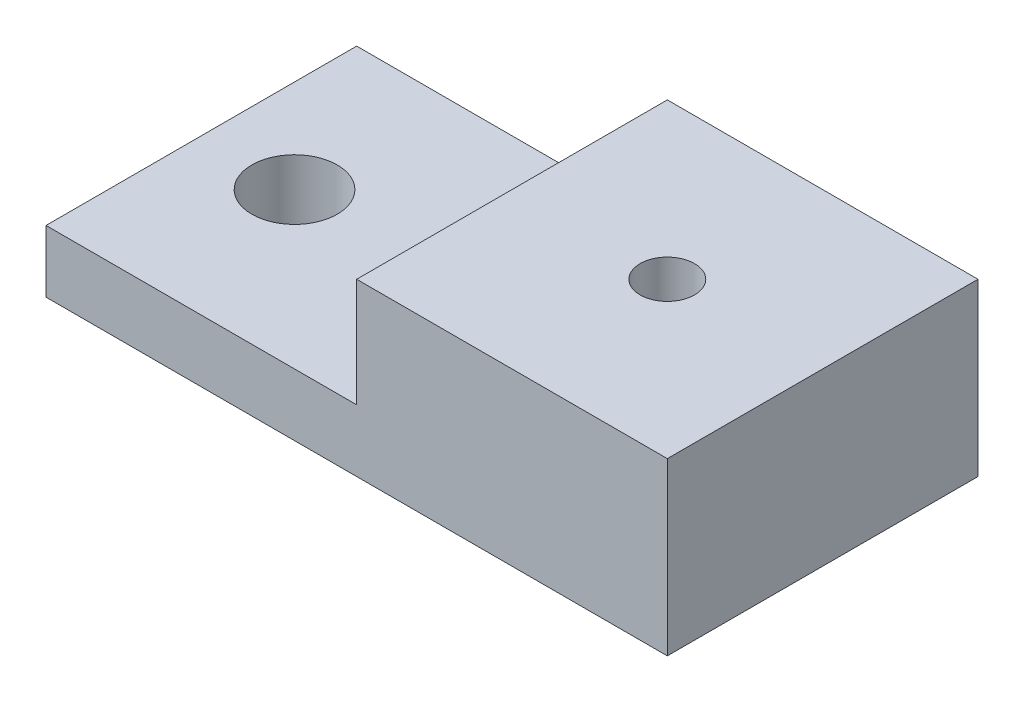
from build123d import *

# Parameters (mm, degrees)
SKETCH1_W           = 40
SKETCH1_H           = 20
SKETCH1_R           = 2.75
BOSS_EXTRUDE1_DEPTH = 4
SKETCH2_W           = 20
SKETCH2_H           = 20
BOSS_EXTRUDE2_DEPTH = 7
SKETCH3_R           = 1.75
CUT_EXTRUDE1_DEPTH  = 12
CUT_EXTRUDE2_DEPTH  = 7


with BuildPart() as part:
    # Sketch1 → Boss-Extrude1 (new body)
    with BuildSketch(Plane(origin=(0, 0, 0), x_dir=(1, 0, 0), z_dir=(0, 1, 0))):
        with Locations((20, 10)):
            Rectangle(SKETCH1_W, SKETCH1_H)
        with Locations((6, 10)):
            Circle(SKETCH1_R, mode=Mode.SUBTRACT)
    extrude(amount=BOSS_EXTRUDE1_DEPTH)

    # Sketch2 → Boss-Extrude2 (add)
    with BuildSketch(Plane(origin=(0, 4, 0), x_dir=(1, 0, 0), z_dir=(0, 1, 0))):
        with Locations((30, 10)):
            Rectangle(SKETCH2_W, SKETCH2_H)
    extrude(amount=BOSS_EXTRUDE2_DEPTH)

    # Sketch3 → Cut-Extrude1 (cut, through all)
    with BuildSketch(Plane(origin=(0, 11, 0), x_dir=(1, 0, 0), z_dir=(0, 1, 0))):
        with Locations((30, 10)):
            Circle(SKETCH3_R)
    extrude(amount=-CUT_EXTRUDE1_DEPTH, mode=Mode.SUBTRACT)

    # Sketch4 → Cut-Extrude2 (cut)
    with BuildSketch(Plane(origin=(0, 0, 0), x_dir=(-1, 0, 0), z_dir=(0, -1, 0))):
        Polygon((-30, 13.218727751), (-32.7875, 11.609363875), (-32.7875, 8.390636125), (-30, 6.781272249), (-27.2125, 8.390636125), (-27.2125, 11.609363875), align=None)
    extrude(amount=-CUT_EXTRUDE2_DEPTH, mode=Mode.SUBTRACT)


solid = part.part
